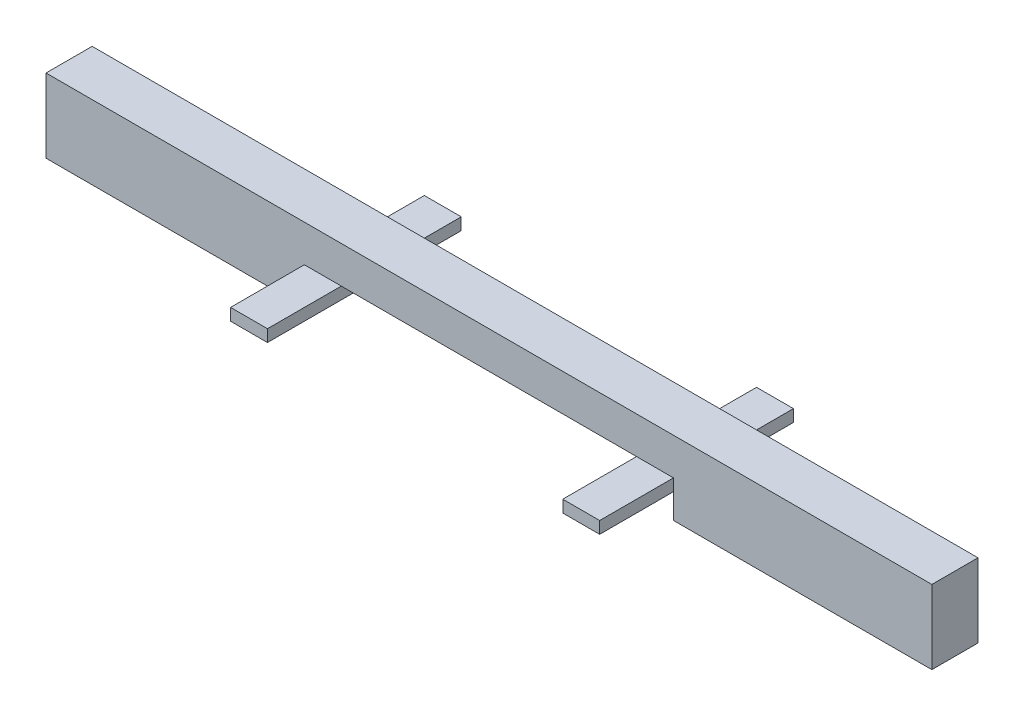
from build123d import *

# Parameters (mm, degrees)
BOSS_EXTRUDE1_DEPTH = 1.25
SKETCH2_W           = 1
SKETCH2_H           = 0.325
BOSS_EXTRUDE2_DEPTH = 2
SKETCH3_W           = 1
SKETCH3_H           = 0.325
BOSS_EXTRUDE3_DEPTH = 2


with BuildPart() as part:
    # Sketch1 → Boss-Extrude1 (new body)
    with BuildSketch(Plane.XY):
        Polygon((1, 0), (9, 0), (9, -0.325), (10, -0.325), (10, -1), (17, -1), (17, 1), (10, 1), (0, 1), (-7, 1), (-7, -1), (0, -1), (0, -0.325), (1, -0.325), align=None)
    extrude(amount=BOSS_EXTRUDE1_DEPTH)

    # Sketch2 → Boss-Extrude2 (add)
    with BuildSketch(Plane.XY.offset(1.25)):
        with Locations((0.5, -0.1625)):
            Rectangle(SKETCH2_W, SKETCH2_H)
        with Locations((9.5, -0.1625)):
            Rectangle(SKETCH2_W, SKETCH2_H)
    extrude(amount=BOSS_EXTRUDE2_DEPTH)

    # Sketch3 → Boss-Extrude3 (add)
    with BuildSketch(Plane(origin=(0, 0, 0), x_dir=(-1, 0, 0), z_dir=(0, 0, -1))):
        with Locations((-9.5, -0.1625)):
            Rectangle(SKETCH3_W, SKETCH3_H)
        with Locations((-0.5, -0.1625)):
            Rectangle(SKETCH3_W, SKETCH3_H)
    extrude(amount=BOSS_EXTRUDE3_DEPTH)


solid = part.part
